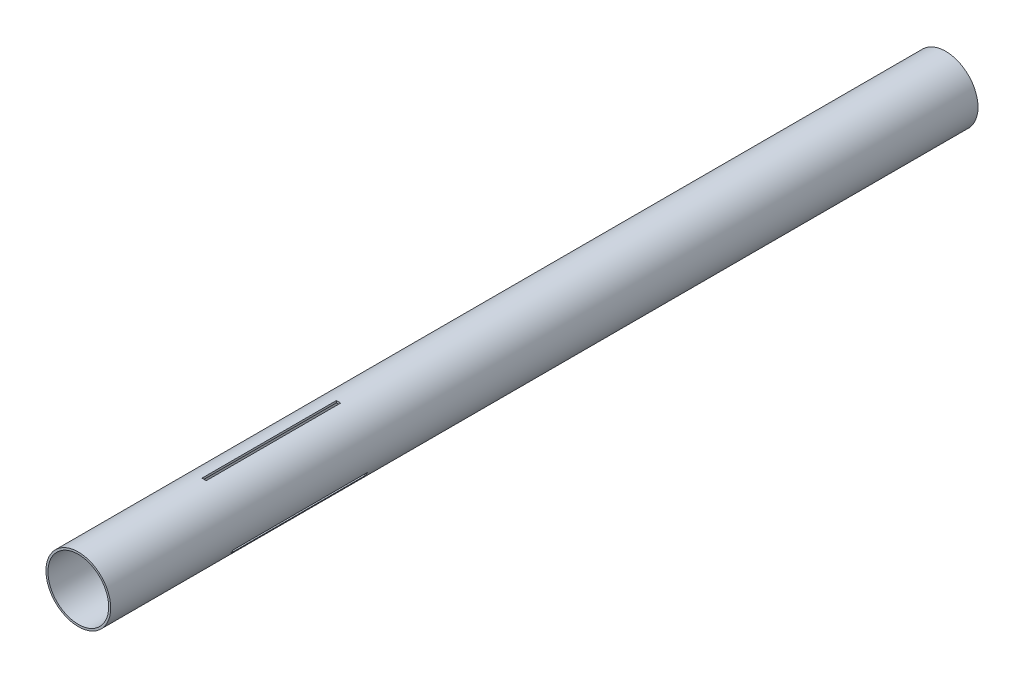
from build123d import *

# Parameters (mm, degrees)
SKETCH1_R           = 23.6982
SKETCH1_R_2         = 22.225
BOSS_EXTRUDE1_DEPTH = 635
CUT_EXTRUDE1_START  = -77.831769
SKETCH2_W           = 3.175
SKETCH2_H           = 98.425
CUT_EXTRUDE1_DEPTH  = 1.529969
CIRPATTERN2_COUNT   = 3


with BuildPart() as part:
    # Sketch1 → Boss-Extrude1 (new body)
    with BuildSketch(Plane.XY):
        Circle(SKETCH1_R)
        Circle(SKETCH1_R_2, mode=Mode.SUBTRACT)
    extrude(amount=BOSS_EXTRUDE1_DEPTH)

    # Sketch2 → Cut-Extrude1 (cut)
    with BuildSketch(Plane(origin=(0, 100, 0), x_dir=(1, 0, 0), z_dir=(0, 1, 0)).offset(CUT_EXTRUDE1_START)):
        with Locations((0, -493.7125)):
            Rectangle(SKETCH2_W, SKETCH2_H)
    cut_extrude1 = extrude(amount=CUT_EXTRUDE1_DEPTH, mode=Mode.SUBTRACT)

    # CirPattern2: Cut-Extrude1 ×3 about axis
    cirpattern2_axis = Axis((0, 0, 0), (0, 0, 1))
    for i in range(1, CIRPATTERN2_COUNT):
        add(cut_extrude1.rotate(cirpattern2_axis, i * 360 / CIRPATTERN2_COUNT), mode=Mode.SUBTRACT)


solid = part.part
